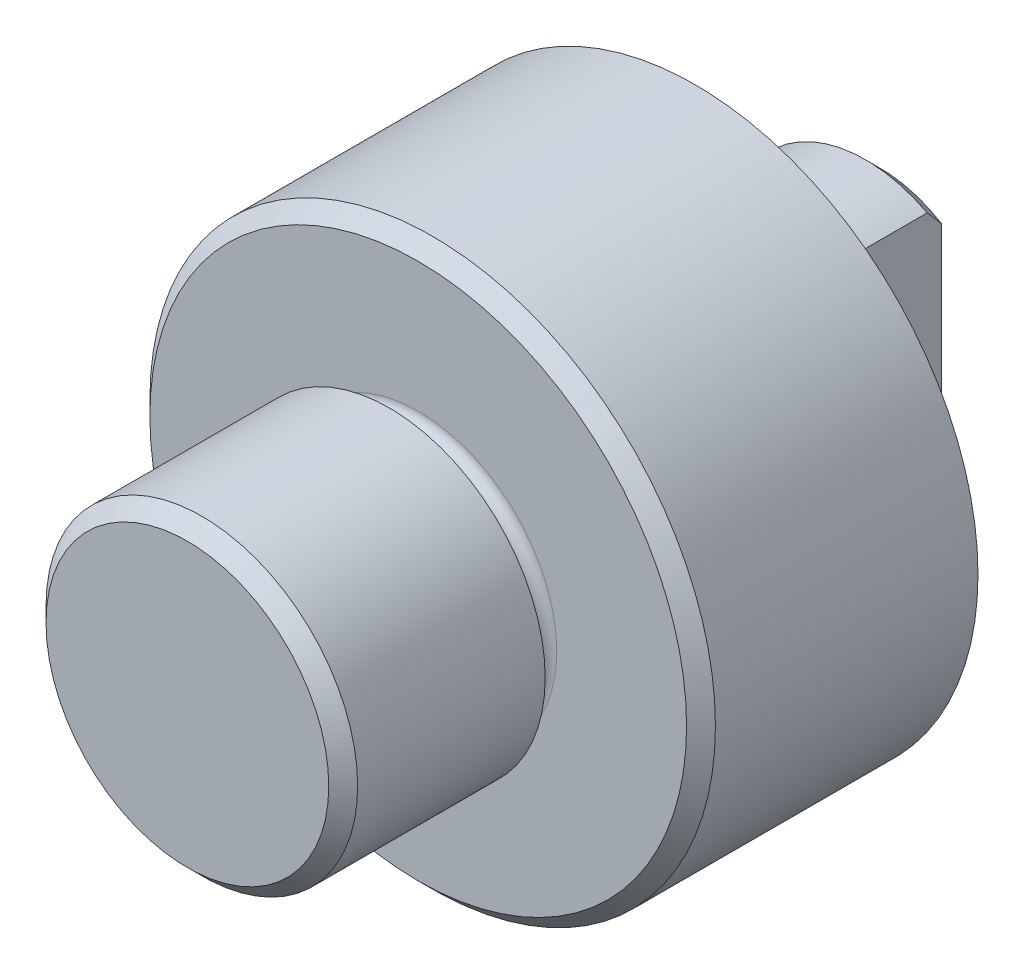
from build123d import *

# Parameters (mm, degrees)
CHAMFER1_SIZE      = 2.5
CUT_EXTRUDE1_DEPTH = 5.5
SKETCH5_W          = 36
SKETCH5_H          = 43
CUT_EXTRUDE2_DEPTH = 12.3
SKETCH6_R          = 6
CUT_EXTRUDE3_DEPTH = 8.4
SKETCH7_R          = 6
FILLET2_R          = 2


with BuildPart() as part:
    # Sketch1 → Revolve1 (revolve)
    with BuildSketch(Plane(origin=(0, 0, 0), x_dir=(0, 0, -1), z_dir=(1, 0, 0))):
        Polygon((-70, 0), (-70, 27), (-35, 27), (-35, 22), (-30, 22), (-30, 49), (18, 49), (18, 23), (50, 23), (50, 0), align=None)
    revolve(axis=Axis((0, 0, 127.018539307), (0, 0, -1)))

    # Chamfer1
    chamfer1_edges = [part.edges().sort_by_distance(p)[0] for p in [
        (0, -27, 70),
        (0, -23, -50),
        (0, -49, 30),
    ]]
    chamfer(chamfer1_edges, length=CHAMFER1_SIZE)

    # Sketch3 → Cut-Extrude1 (cut)
    with BuildSketch(Plane(origin=(0, -49, 0), x_dir=(-1, 0, 0), z_dir=(0, -1, 0))):
        with BuildLine():
            Line((-4, -18), (-4, 10))
            ThreePointArc((-4, 10), (0, 14), (4, 10))
            Line((4, 10), (4, -18))
            ThreePointArc((4, -18), (0, -22), (-4, -18))
        make_face()
    extrude(amount=-CUT_EXTRUDE1_DEPTH, mode=Mode.SUBTRACT)

    # Sketch5 → Cut-Extrude2 (cut)
    with BuildSketch(Plane(origin=(10.7, 0, 0), x_dir=(0, 0, -1), z_dir=(1, 0, 0))):
        with Locations((36, 1.5)):
            Rectangle(SKETCH5_W, SKETCH5_H)
    extrude(amount=CUT_EXTRUDE2_DEPTH, mode=Mode.SUBTRACT)

    # Sketch6 → Cut-Extrude3 (cut)
    with BuildSketch(Plane(origin=(10.7, 0, 0), x_dir=(0, 0, -1), z_dir=(1, 0, 0))):
        with Locations((33, 0)):
            Circle(SKETCH6_R)
    extrude(amount=-CUT_EXTRUDE3_DEPTH, mode=Mode.SUBTRACT)

    # Sketch7 → Cut-Loft1 section 0
    with BuildSketch(Plane(origin=(2.3, 0, 0), x_dir=(0, 0, -1), z_dir=(1, 0, 0)), mode=Mode.PRIVATE) as cut_loft1_s0:
        with Locations((33, 0)):
            Circle(SKETCH7_R)
    loft([Vertex(0, 0, -33), cut_loft1_s0.sketch], mode=Mode.SUBTRACT)

    # Fillet2
    fillet2_edges = [part.edges().sort_by_distance(p)[0] for p in [
        (0, -22, 30),
        (0, -22, 35),
    ]]
    fillet(fillet2_edges, radius=FILLET2_R)


solid = part.part
